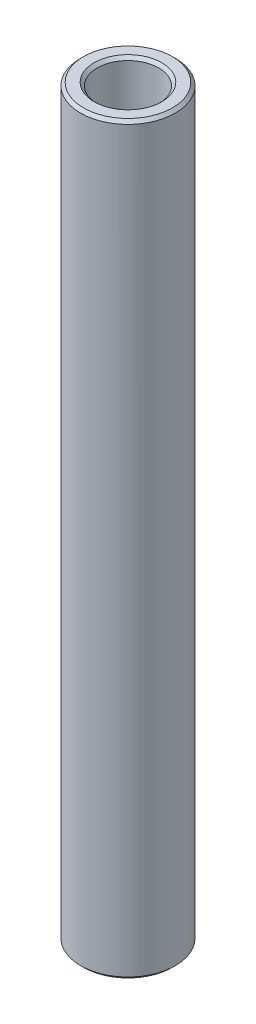
from build123d import *

# Parameters (mm, degrees)
SKETCH1_W     = 0.7
SKETCH1_H     = 31.38678
CHAMFER1_SIZE = 0.127


with BuildPart() as part:
    # Sketch1 → Revolve1 (revolve)
    with BuildSketch(Plane.XY):
        with Locations((1.65, 0)):
            Rectangle(SKETCH1_W, SKETCH1_H)
    revolve(axis=Axis((0, 9.615558323, 0), (0, -1, 0)))

    # Chamfer1
    chamfer1_edges = [part.edges().sort_by_distance(p)[0] for p in [
        (-1.3, 15.69339, 0),
        (-2, 15.69339, 0),
        (-2, -15.69339, 0),
        (-1.3, -15.69339, 0),
    ]]
    chamfer(chamfer1_edges, length=CHAMFER1_SIZE)


solid = part.part
